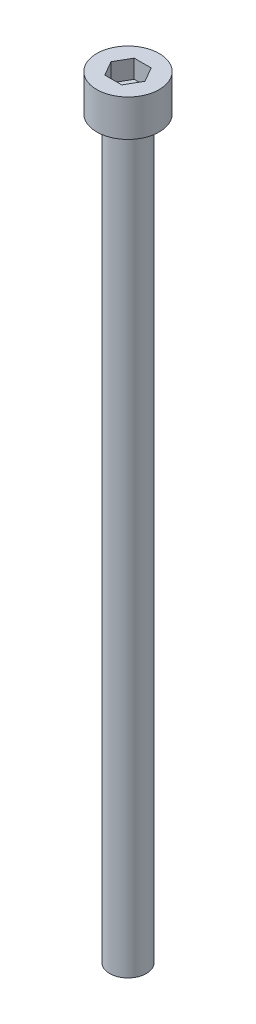
from build123d import *

# Parameters (mm, degrees)
SKETCH_1_R          = 4.25
EXTRUDE_1_DEPTH     = 5
CUT_EXTRUDE_1_DEPTH = 2.5
SKETCH_3_R          = 2.5
EXTRUDE_2_DEPTH     = 100


with BuildPart() as part:
    # 草图1 → 凸台-拉伸1 (new body)
    with BuildSketch(Plane(origin=(0, 0, 0), x_dir=(1, 0, 0), z_dir=(0, 1, 0))):
        Circle(SKETCH_1_R)
    extrude(amount=EXTRUDE_1_DEPTH)

    # 草图2 → 切除-拉伸1 (cut)
    with BuildSketch(Plane(origin=(0, 5, 0), x_dir=(1, 0, 0), z_dir=(0, 1, 0))):
        Polygon((2.309401077, 0), (1.154700538, 2), (-1.154700538, 2), (-2.309401077, 0), (-1.154700538, -2), (1.154700538, -2), align=None)
    extrude(amount=-CUT_EXTRUDE_1_DEPTH, mode=Mode.SUBTRACT)

    # 草图3 → 凸台-拉伸2 (add)
    with BuildSketch(Plane.XZ):
        Circle(SKETCH_3_R)
    extrude(amount=EXTRUDE_2_DEPTH)


solid = part.part
